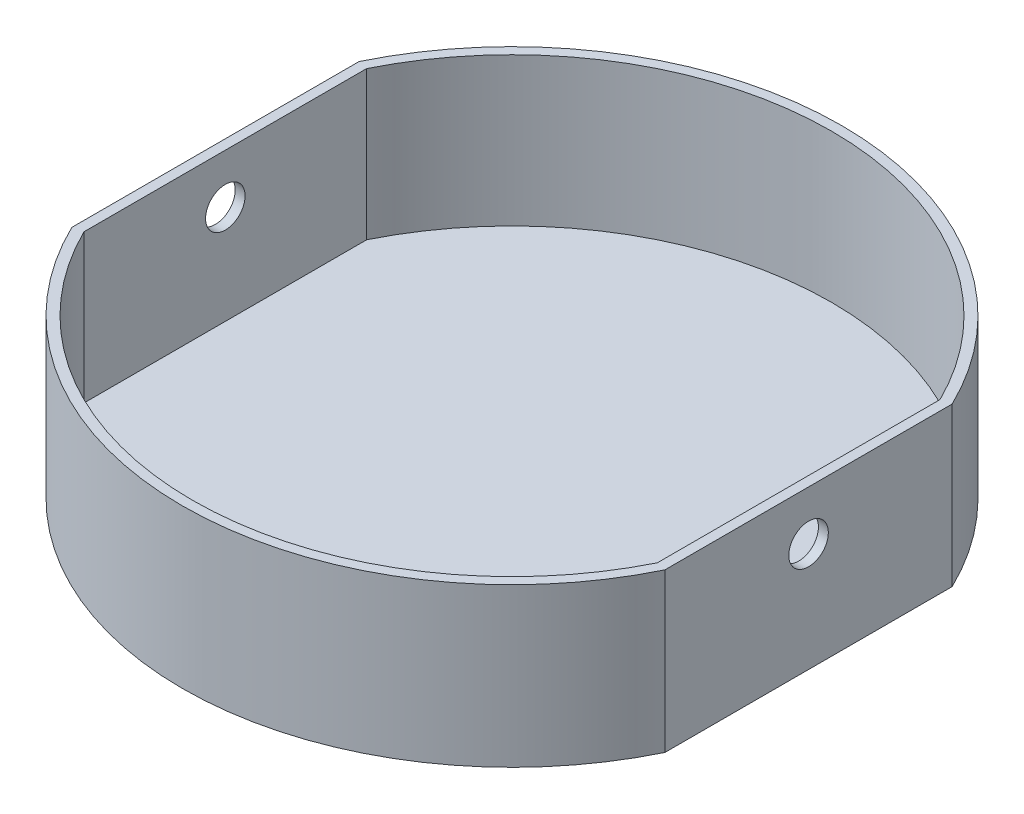
from build123d import *

# Parameters (mm, degrees)
SKETCH1_R           = 100
BOSS_EXTRUDE2_DEPTH = 3
SKETCH5_W           = 3
SKETCH5_H           = 87
BOSS_EXTRUDE5_DEPTH = 45
SKETCH8_W           = 3
SKETCH8_H           = 87
BOSS_EXTRUDE6_DEPTH = 45
SKETCH9_W           = 23.719660605
SKETCH9_H           = 94.301811056
CUT_EXTRUDE2_DEPTH  = 45
SKETCH10_W          = 23.969699351
SKETCH10_H          = 92.447375273
CUT_EXTRUDE3_DEPTH  = 45
SKETCH11_R          = 6
CUT_EXTRUDE4_DEPTH  = 45
SKETCH12_R          = 6
CUT_EXTRUDE5_DEPTH  = 45
BOSS_EXTRUDE7_DEPTH = 45
CUT_EXTRUDE6_DEPTH  = 45


with BuildPart() as part:
    # Sketch1 → Boss-Extrude2 (new body)
    with BuildSketch(Plane(origin=(0, 0, 0), x_dir=(1, 0, 0), z_dir=(0, 1, 0))):
        with Locations(Location((0, 0, 0), (0, 0, 270))):
            Circle(SKETCH1_R)
    extrude(amount=BOSS_EXTRUDE2_DEPTH)

    # Sketch5 → Boss-Extrude5 (add)
    with BuildSketch(Plane(origin=(0, 3, 0), x_dir=(1, 0, 0), z_dir=(0, 1, 0))):
        with Locations((88.5, 0.088989435)):
            Rectangle(SKETCH5_W, SKETCH5_H)
    extrude(amount=BOSS_EXTRUDE5_DEPTH)

    # Sketch8 → Boss-Extrude6 (add)
    with BuildSketch(Plane(origin=(0, 3, 0), x_dir=(1, 0, 0), z_dir=(0, 1, 0))):
        with Locations((-88.5, 0.088989435)):
            Rectangle(SKETCH8_W, SKETCH8_H)
    extrude(amount=BOSS_EXTRUDE6_DEPTH)

    # Sketch9 → Cut-Extrude2 (cut)
    with BuildSketch(Plane(origin=(0, 3, 0), x_dir=(1, 0, 0), z_dir=(0, 1, 0))):
        with Locations((101.859830303, -3.561916093)):
            Rectangle(SKETCH9_W, SKETCH9_H)
    extrude(amount=-CUT_EXTRUDE2_DEPTH, mode=Mode.SUBTRACT)

    # Sketch10 → Cut-Extrude3 (cut)
    with BuildSketch(Plane(origin=(0, 3, 0), x_dir=(1, 0, 0), z_dir=(0, 1, 0))):
        with Locations((-101.984849676, 2.812677071)):
            Rectangle(SKETCH10_W, SKETCH10_H)
    extrude(amount=-CUT_EXTRUDE3_DEPTH, mode=Mode.SUBTRACT)

    # Sketch11 → Cut-Extrude4 (cut)
    with BuildSketch(Plane.ZY.offset(90)):
        with Locations((0, 33)):
            Circle(SKETCH11_R)
    extrude(amount=-CUT_EXTRUDE4_DEPTH, mode=Mode.SUBTRACT)

    # Sketch12 → Cut-Extrude5 (cut)
    with BuildSketch(Plane(origin=(90, 0, 0), x_dir=(0, 0, -1), z_dir=(1, 0, 0))):
        with Locations(Location((0, 33, 0), (0, 0, 180))):
            Circle(SKETCH12_R)
    extrude(amount=-CUT_EXTRUDE5_DEPTH, mode=Mode.SUBTRACT)

    # Sketch14 → Boss-Extrude7 (add)
    with BuildSketch(Plane(origin=(0, 3, 0), x_dir=(1, 0, 0), z_dir=(0, 1, 0))):
        with BuildLine():
            Line((-90, -43.411010565), (-90.085982049, -43.411010565))
            ThreePointArc((-90.085982049, -43.411010565), (-0.098829893, -99.999951163), (90, -43.588989435))
            Line((90, -43.588989435), (90, -43.411010565))
            Line((90, -43.411010565), (87, -43.411010565))
            Line((87, -43.411010565), (87, 43.588989435))
            Line((87, 43.588989435), (90, 43.588989435))
            ThreePointArc((90, 43.588989435), (0, 100), (-90, 43.588989435))
            Line((-90, 43.588989435), (-87, 43.588989435))
            Line((-87, 43.588989435), (-87, -43.411010565))
            Line((-87, -43.411010565), (-90, -43.411010565))
        make_face()
    extrude(amount=BOSS_EXTRUDE7_DEPTH)

    # 3DSketch1 → Cut-Extrude6 (cut)
    with BuildSketch(Plane(origin=(-87, 48, -42.895221179), x_dir=(0.8969072164948455, 0, 0.4422187750417981), z_dir=(0, -1, 0))):
        with BuildLine():
            Line((0, 0), (37.93814433, 76.946066857))
            ThreePointArc((37.93814433, 76.946066857), (139.895221179, 87), (194, 0))
            Line((194, 0), (156.06185567, -76.946066857))
            ThreePointArc((156.06185567, -76.946066857), (54.104778821, -87), (0, 0))
        make_face()
    extrude(amount=CUT_EXTRUDE6_DEPTH, mode=Mode.SUBTRACT)


solid = part.part
